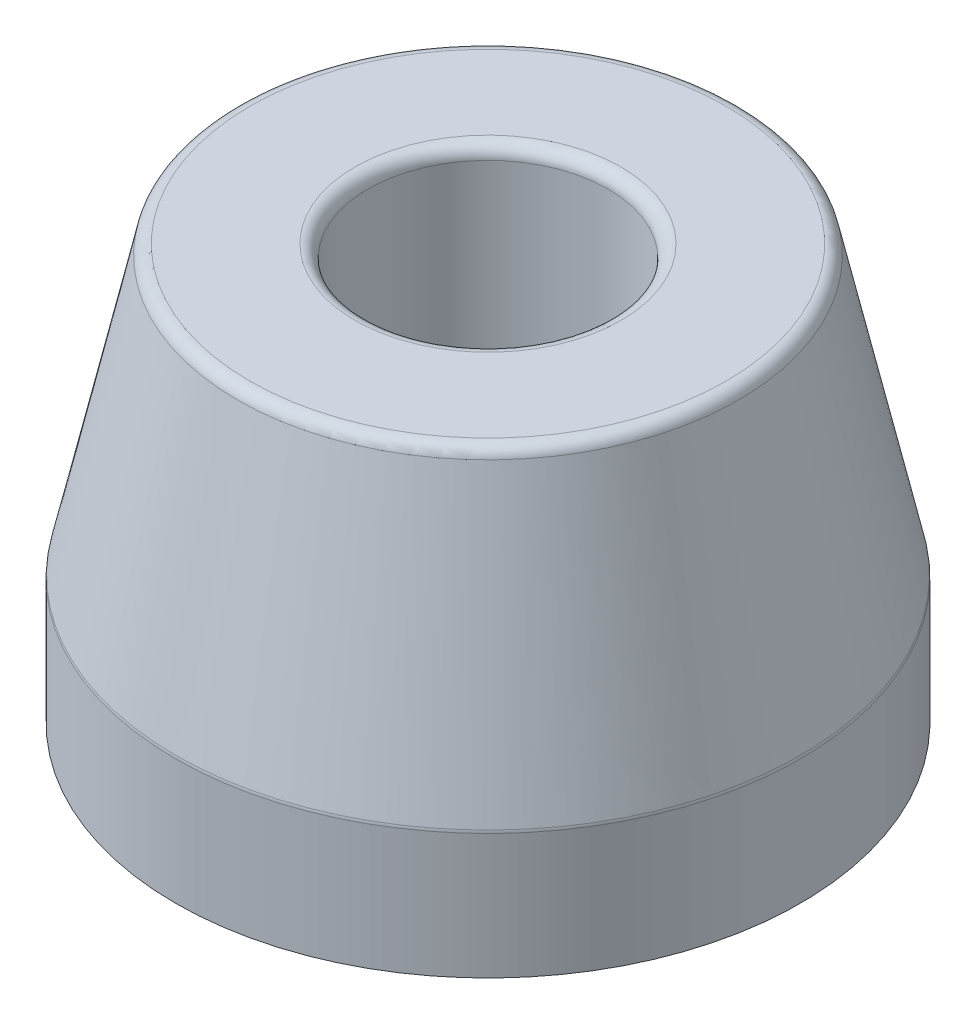
from build123d import *


with BuildPart() as part:
    # Sketch1 → Revolve1 (revolve)
    with BuildSketch(Plane.XY):
        with BuildLine():
            Line((4.7625, 0), (4.7625, 15.937))
            ThreePointArc((4.7625, 15.937), (4.911289755, 16.296210245), (5.2705, 16.445))
            Line((5.2705, 16.445), (9.434996824, 16.445))
            ThreePointArc((9.434996824, 16.445), (9.75286634, 16.333261241), (9.930899851, 16.047200673))
            Line((9.930899851, 16.047200673), (12.370403027, 5.06943638))
            ThreePointArc((12.370403027, 5.06943638), (12.379466701, 5.014667028), (12.3825, 4.959235708))
            Line((12.3825, 4.959235708), (12.3825, 0))
            Line((12.3825, 0), (4.7625, 0))
        make_face()
    revolve(axis=Axis((0, 0, 0), (0, 1, 0)))


solid = part.part
